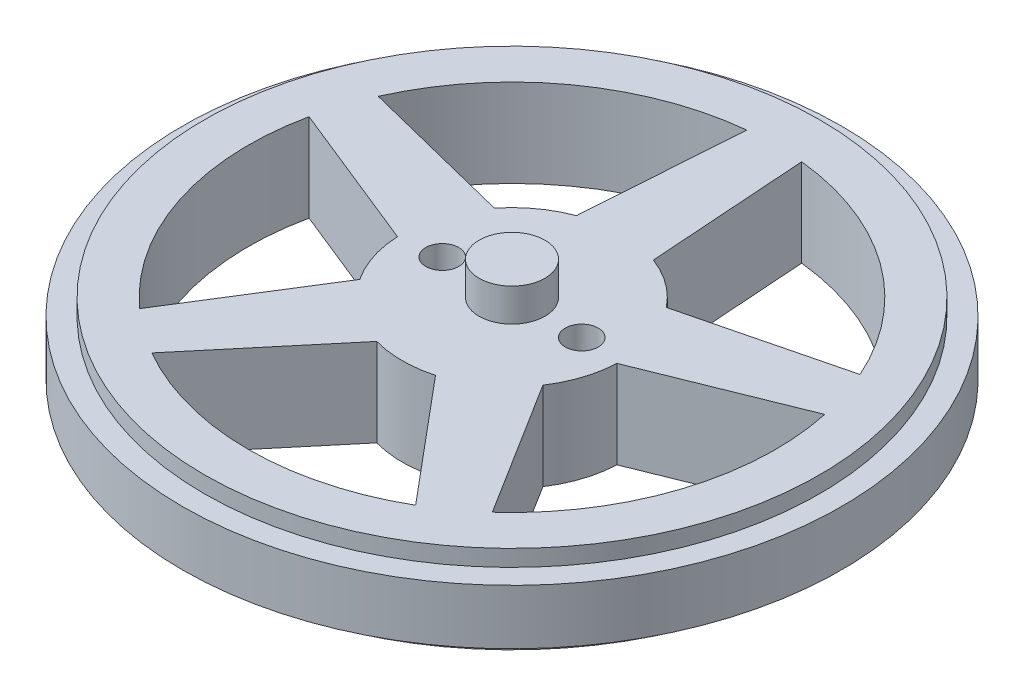
from build123d import *

# Parameters (mm, degrees)
SKETCH1_R           = 28
BOSS_EXTRUDE1_DEPTH = 8
SKETCH2_R           = 1.5
CUT_EXTRUDE1_DEPTH  = 8
SKETCH3_W           = 2
SKETCH3_H           = 5
SKETCH4_R           = 3
BOSS_EXTRUDE2_DEPTH = 3


with BuildPart() as part:
    # Sketch1 → Boss-Extrude1 (new body)
    with BuildSketch(Plane(origin=(0, 0, 0), x_dir=(1, 0, 0), z_dir=(0, 1, 0))):
        with Locations(Location((0, 0, 0), (0, 0, 270))):
            Circle(SKETCH1_R)
        with BuildLine():
            Line((-2.5, 23.869436525), (-3.5, 9.367496998))
            ThreePointArc((-3.5, 9.367496998), (-5.877852523, 8.090169944), (-7.827459581, 6.223413574))
            Line((-7.827459581, 6.223413574), (-21.928640661, 9.753702823))
            ThreePointArc((-21.928640661, 9.753702823), (-14.106846055, 19.416407865), (-2.5, 23.869436525))
        make_face(mode=Mode.SUBTRACT)
        with BuildLine():
            Line((3.5, 9.367496998), (2.5, 23.869436525))
            ThreePointArc((2.5, 23.869436525), (14.106846055, 19.416407865), (21.928640661, 9.753702823))
            Line((21.928640661, 9.753702823), (7.827459581, 6.223413574))
            ThreePointArc((7.827459581, 6.223413574), (5.877852523, 8.090169944), (3.5, 9.367496998))
        make_face(mode=Mode.SUBTRACT)
        with BuildLine():
            Line((9.990578541, -0.43398204), (23.473725633, 4.998420242))
            ThreePointArc((23.473725633, 4.998420242), (22.825356391, -7.416407865), (16.052645256, -17.841316664))
            Line((16.052645256, -17.841316664), (8.337636066, -5.521215883))
            ThreePointArc((8.337636066, -5.521215883), (9.510565163, -3.090169944), (9.990578541, -0.43398204))
        make_face(mode=Mode.SUBTRACT)
        with BuildLine():
            Line((2.674517106, -9.635712649), (12.007560284, -20.780242925))
            ThreePointArc((12.007560284, -20.780242925), (0, -24), (-12.007560284, -20.780242925))
            Line((-12.007560284, -20.780242925), (-2.674517106, -9.635712649))
            ThreePointArc((-2.674517106, -9.635712649), (0, -10), (2.674517106, -9.635712649))
        make_face(mode=Mode.SUBTRACT)
        with BuildLine():
            Line((-8.337636066, -5.521215883), (-16.052645256, -17.841316664))
            ThreePointArc((-16.052645256, -17.841316664), (-22.825356391, -7.416407865), (-23.473725633, 4.998420242))
            Line((-23.473725633, 4.998420242), (-9.990578541, -0.43398204))
            ThreePointArc((-9.990578541, -0.43398204), (-9.510565163, -3.090169944), (-8.337636066, -5.521215883))
        make_face(mode=Mode.SUBTRACT)
    extrude(amount=BOSS_EXTRUDE1_DEPTH)

    # Sketch2 → Cut-Extrude1 (cut)
    with BuildSketch(Plane(origin=(0, 8, 0), x_dir=(1, 0, 0), z_dir=(0, 1, 0))):
        with Locations(Location((-6.35, 0, 0), (0, 0, 270))):
            Circle(SKETCH2_R)
        with Locations(Location((6.35, 0, 0), (0, 0, 270))):
            Circle(SKETCH2_R)
    extrude(amount=-CUT_EXTRUDE1_DEPTH, mode=Mode.SUBTRACT)

    # Sweep1: sweep along a curve in space
    with BuildLine() as sweep1_path:
        ThreePointArc((0, 8, 28), (19.798989873, 8, 19.798989873), (28, 8, 0))
        ThreePointArc((28, 8, 0), (19.798989873, 8, -19.798989873), (0, 8, -28))
        ThreePointArc((0, 8, -28), (-19.798989873, 8, -19.798989873), (-28, 8, 0))
        ThreePointArc((-28, 8, 0), (-19.798989873, 8, 19.798989873), (0, 8, 28))
    # Sketch3 → Sweep1 (sweep)
    with BuildSketch(Plane(origin=(0, 0, 0), x_dir=(0, 0, -1), z_dir=(1, 0, 0))):
        with Locations((29, 4)):
            Rectangle(SKETCH3_W, SKETCH3_H)
    sweep(path=sweep1_path.line)

    # Sketch4 → Boss-Extrude2 (add)
    with BuildSketch(Plane(origin=(0, 8, 0), x_dir=(1, 0, 0), z_dir=(0, 1, 0))):
        with Locations(Location((0, 0, 0), (0, 0, 270))):
            Circle(SKETCH4_R)
    extrude(amount=BOSS_EXTRUDE2_DEPTH)


solid = part.part
